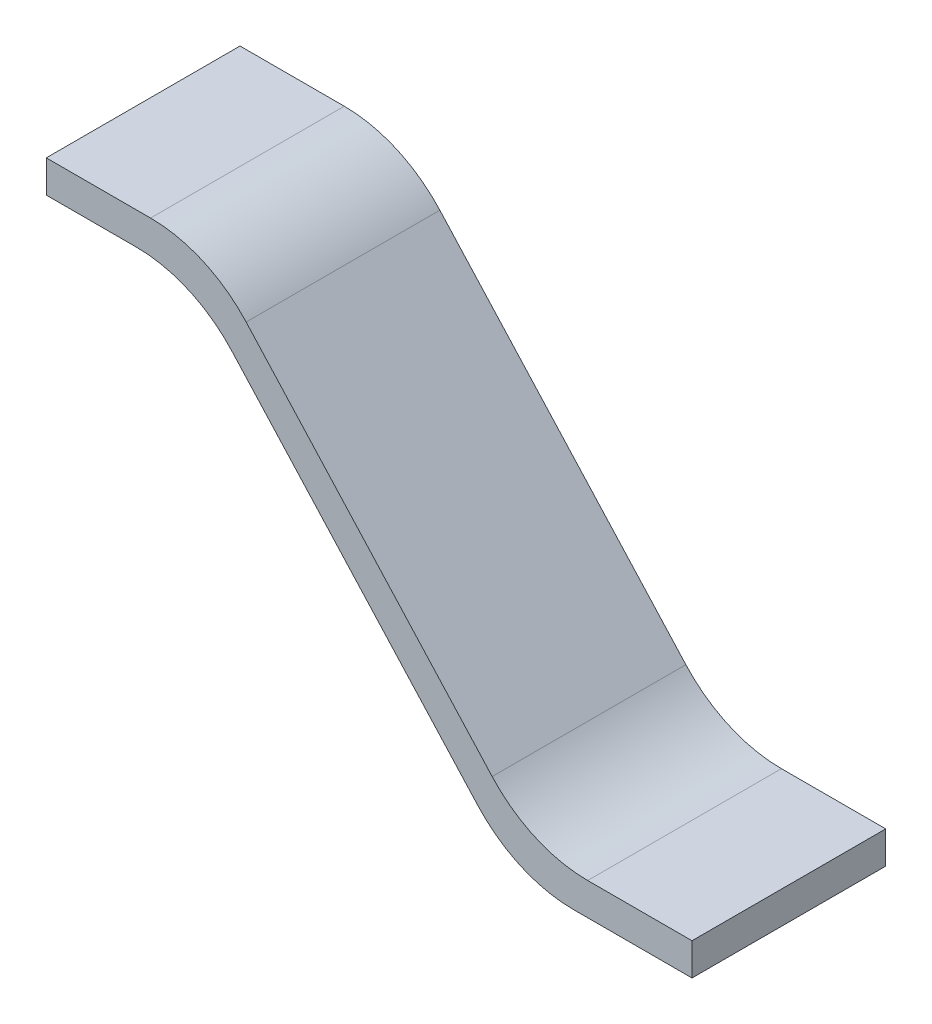
from build123d import *

# Parameters (mm, degrees)
BOSS_EXTRUDE1_DEPTH = 0.15
FILLET4_R           = 0.2


with BuildPart() as part:
    # Sketch4 → Boss-Extrude1 (new body, symmetric)
    with BuildSketch(Plane.XY):
        Polygon((0, 0), (0.25, 0), (0.75, -0.55), (1, -0.55), (1, -0.6), (0.727881506, -0.6), (0.227881506, -0.05), (0, -0.05), align=None)
    extrude(amount=BOSS_EXTRUDE1_DEPTH, both=True)

    # Fillet4
    fillet4_edges = [part.edges().sort_by_distance(p)[0] for p in [
        (0.25, 0, 0),
        (0.75, -0.55, 0),
        (0.727881506, -0.6, 0),
        (0.227881506, -0.05, 0),
    ]]
    fillet(fillet4_edges, radius=FILLET4_R)


solid = part.part
